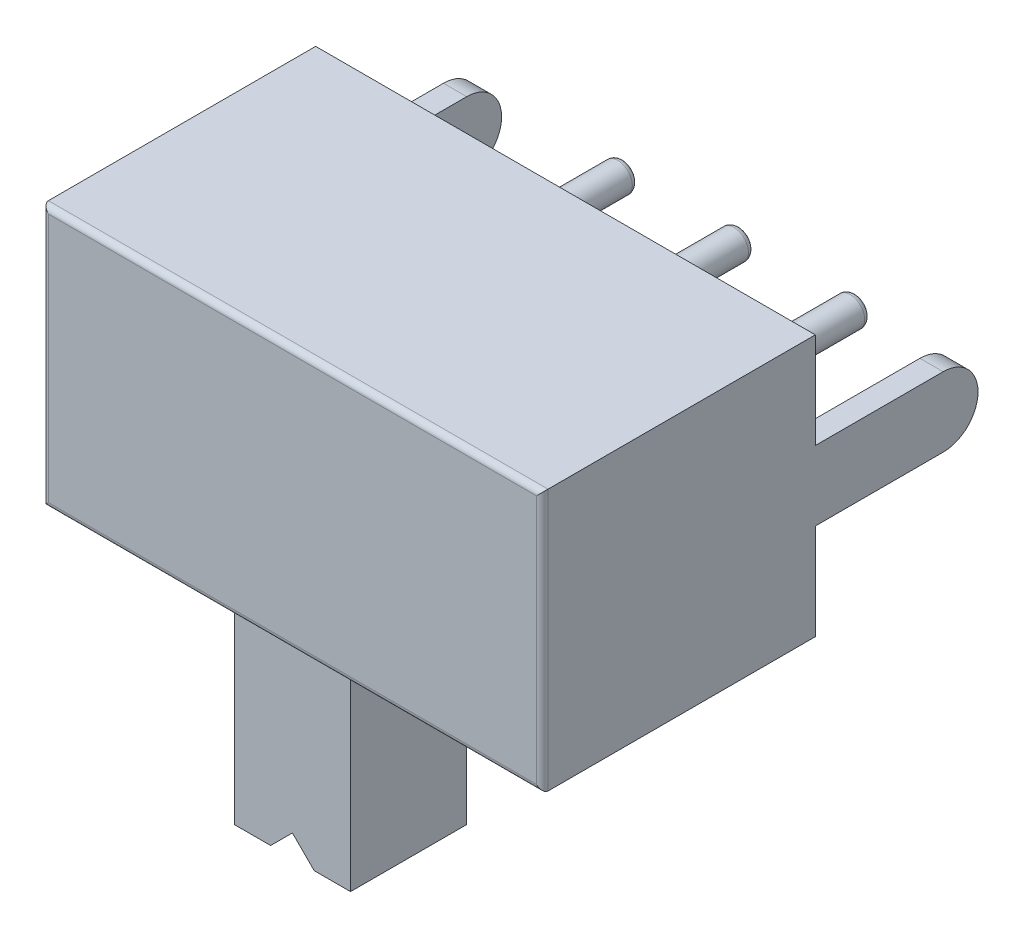
from build123d import *

# Parameters (mm, degrees)
SKETCH1_W           = 8.6
SKETCH1_H           = 4.5
BOSS_EXTRUDE1_DEPTH = 4.7
SKETCH2_W           = 4.1
SKETCH2_H           = 2.5
CUT_EXTRUDE1_DEPTH  = 0.5
BOSS_EXTRUDE2_DEPTH = 0.4
SKETCH4_R           = 0.25
BOSS_EXTRUDE3_DEPTH = 3
SKETCH5_W           = 2
SKETCH5_H           = 2
BOSS_EXTRUDE4_DEPTH = 4.6
CUT_EXTRUDE2_REACH  = 8.7
FILLET2_R           = 0.1


with BuildPart() as part:
    # Sketch1 → Boss-Extrude1 (new body)
    with BuildSketch(Plane.XY):
        Rectangle(SKETCH1_W, SKETCH1_H)
    extrude(amount=BOSS_EXTRUDE1_DEPTH)

    # Sketch2 → Cut-Extrude1 (cut)
    with BuildSketch(Plane.XZ.offset(2.25)):
        with Locations((0, 2.7)):
            Rectangle(SKETCH2_W, SKETCH2_H)
    extrude(amount=-CUT_EXTRUDE1_DEPTH, mode=Mode.SUBTRACT)

    # Sketch3 → Boss-Extrude2 (add)
    with BuildSketch(Plane(origin=(4.3, 0, 0), x_dir=(0, 0, -1), z_dir=(1, 0, 0))):
        with BuildLine():
            Line((0, 0.6), (0, -0.6))
            Line((0, -0.6), (2.2, -0.6))
            ThreePointArc((2.2, -0.6), (2.8, 0), (2.2, 0.6))
            Line((2.2, 0.6), (0, 0.6))
        make_face()
    boss_extrude2 = extrude(amount=-BOSS_EXTRUDE2_DEPTH)

    # Mirror1: Boss-Extrude2 across plane
    add(boss_extrude2.mirror(Plane(origin=(0, 0, 0), x_dir=(0, 0, 1), z_dir=(1, 0, 0))))

    # Sketch4 → Boss-Extrude3 (add)
    with BuildSketch(Plane(origin=(0, 0, 0), x_dir=(-1, 0, 0), z_dir=(0, 0, -1))):
        with Locations((2, 0)):
            Circle(SKETCH4_R)
        Circle(SKETCH4_R)
        with Locations((-2, 0)):
            Circle(SKETCH4_R)
    extrude(amount=BOSS_EXTRUDE3_DEPTH)

    # Sketch5 → Boss-Extrude4 (add)
    with BuildSketch(Plane.XZ.offset(1.75)):
        with Locations((-1, 2.7)):
            Rectangle(SKETCH5_W, SKETCH5_H)
    extrude(amount=BOSS_EXTRUDE4_DEPTH)

    # Sketch6 → Cut-Extrude2 (cut, up to next)
    with BuildSketch(Plane.XY.offset(3.7), mode=Mode.PRIVATE) as cut_extrude2_sk1:
        Polygon((-1, -5.975), (-1.375, -6.35), (-0.625, -6.35), align=None)
    cut_extrude2_tool1 = extrude(cut_extrude2_sk1.sketch, amount=-CUT_EXTRUDE2_REACH, mode=Mode.PRIVATE) & part.part
    add(cut_extrude2_tool1.solids().sort_by_distance((-1, -6.225, 3.7))[0], mode=Mode.SUBTRACT)

    # Fillet2
    fillet2_edges = [part.edges().sort_by_distance(p)[0] for p in [
        (4.3, 0, 4.7),
        (0, 2.25, 4.7),
        (-4.3, 0, 4.7),
        (-1.75, 0, -3),
        (0.25, 0, -3),
        (2.25, 0, -3),
        (0, -2.25, 4.7),
    ]]
    fillet(fillet2_edges, radius=FILLET2_R)


solid = part.part
